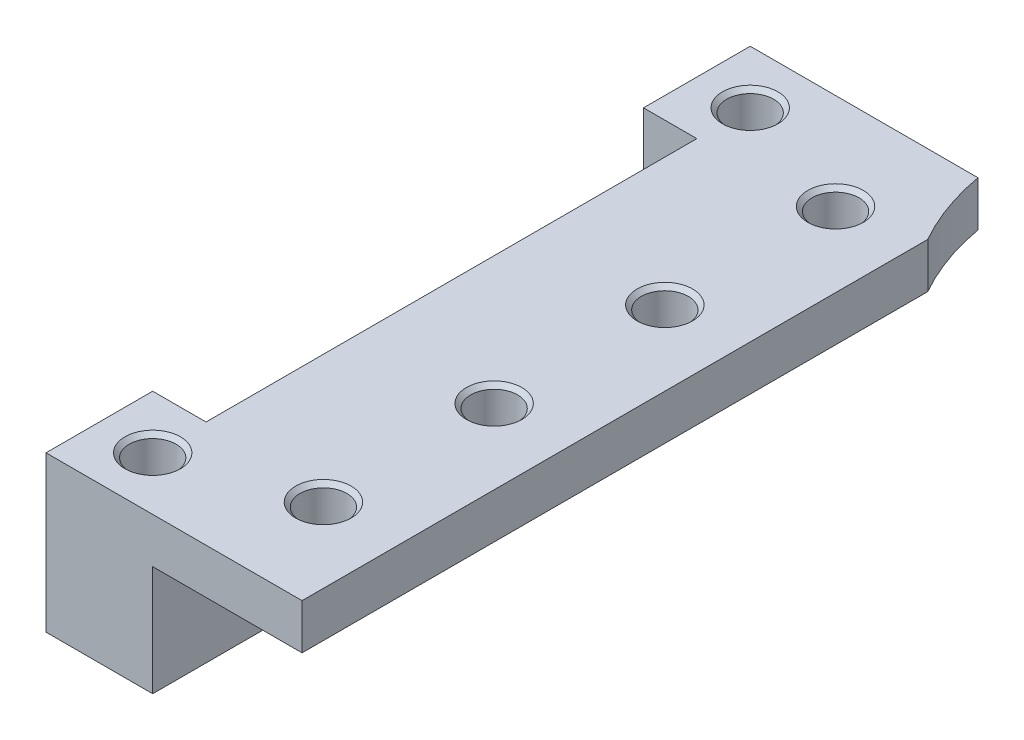
from build123d import *

# Parameters (mm, degrees)
IZIM3_W                                          = 3.5
IZIM3_H                                          = 23
IZIM3_H_2                                        = 5
IZIM3_W_2                                        = 2.5
Y_KSEKLIK_EKSTR_ZYON3_DEPTH                      = 8.28
IZIM4_W                                          = 7
IZIM4_H                                          = 5.16
KES_EKSTR_ZYON1_DEPTH                            = 34
IZIM11_W                                         = 12
IZIM11_H                                         = 33
KES_EKSTR_ZYON2_DEPTH                            = 1
M2_D_Z_BA_L_MAKINE_VIDAS_IN_HAV_A_DE_D           = 2.2
M2_D_Z_BA_L_MAKINE_VIDAS_IN_HAV_A_DE_CSINK_D     = 2.6
M2_D_Z_BA_L_MAKINE_VIDAS_IN_HAV_A_DE_CSINK_ANGLE = 90
IZIM16_W                                         = 12
IZIM16_H                                         = 33
KES_EKSTR_ZYON3_DEPTH                            = 10


with BuildPart() as part:
    # Çizim3 → Yükseklik-Ekstrüzyon3 (new body)
    with BuildSketch(Plane(origin=(0, 0, 0), x_dir=(1, 0, 0), z_dir=(0, 1, 0))):
        with BuildLine():
            Line((16, 6.5), (16, 11.5))
            Line((16, 11.5), (11.324751653, 11.5))
            ThreePointArc((11.324751653, 11.5), (10.819882158, 9.603828792), (10, 7.821091654))
            Line((10, 7.821091654), (10, -21.5))
            Line((10, -21.5), (16, -21.5))
            Line((16, -21.5), (16, -16.5))
            Line((16, -16.5), (16, 6.5))
        make_face()
        with Locations((17.75, -5)):
            Rectangle(IZIM3_W, IZIM3_H)
        with Locations((17.75, 9)):
            Rectangle(IZIM3_W, IZIM3_H_2)
        with Locations((20.75, 9)):
            Rectangle(IZIM3_W_2, IZIM3_H_2)
        with Locations((17.75, -19)):
            Rectangle(IZIM3_W, IZIM3_H_2)
        with Locations((20.75, -19)):
            Rectangle(IZIM3_W_2, IZIM3_H_2)
    y_kseklik_ekstr_zyon3 = extrude(amount=Y_KSEKLIK_EKSTR_ZYON3_DEPTH)

    # Çizim4 → Kes-Ekstrüzyon1 (cut, through all)
    with BuildSketch(Plane.XY.offset(21.5)):
        with Locations((13.5, 2.58)):
            Rectangle(IZIM4_W, IZIM4_H)
    kes_ekstr_zyon1 = extrude(amount=-KES_EKSTR_ZYON1_DEPTH, mode=Mode.SUBTRACT)

    # Çizim11 → Kes-Ekstrüzyon2 (cut)
    with BuildSketch(Plane(origin=(0, 8.28, 0), x_dir=(1, 0, 0), z_dir=(0, 1, 0))):
        with Locations((16, -5)):
            Rectangle(IZIM11_W, IZIM11_H)
    kes_ekstr_zyon2 = extrude(amount=-KES_EKSTR_ZYON2_DEPTH, mode=Mode.SUBTRACT)

    # M2 Düz Başlı Makine Vidası İçin Havşa_ DEĞİŞTİREBİLİRİZ (through all)
    with Locations(Plane(origin=(19.5, 7.28, 19), x_dir=(0, 0, 1), z_dir=(0, 1, 0))):
        with Locations((0, 0), (-28, 0), (-2, -6), (-10, -6), (-18, -6), (-26, -6)):
            m2_d_z_ba_l_makine_vidas_in_hav_a_de = CounterSinkHole(M2_D_Z_BA_L_MAKINE_VIDAS_IN_HAV_A_DE_D / 2, M2_D_Z_BA_L_MAKINE_VIDAS_IN_HAV_A_DE_CSINK_D / 2, counter_sink_angle=M2_D_Z_BA_L_MAKINE_VIDAS_IN_HAV_A_DE_CSINK_ANGLE)

    # Aynalama2: Yükseklik-Ekstrüzyon3, Kes-Ekstrüzyon1, Kes-Ekstrüzyon2, M2 Düz Başlı Makine Vidası İçin Havşa_ DEĞİŞTİREBİLİRİZ across plane
    add(y_kseklik_ekstr_zyon3.mirror(Plane(origin=(10, 8.28, 0), x_dir=(0, 0, 1), z_dir=(-1, 0, 0))))
    add(kes_ekstr_zyon1.mirror(Plane(origin=(10, 8.28, 0), x_dir=(0, 0, 1), z_dir=(-1, 0, 0))), mode=Mode.SUBTRACT)
    add(kes_ekstr_zyon2.mirror(Plane(origin=(10, 8.28, 0), x_dir=(0, 0, 1), z_dir=(-1, 0, 0))), mode=Mode.SUBTRACT)
    add(m2_d_z_ba_l_makine_vidas_in_hav_a_de.mirror(Plane(origin=(10, 8.28, 0), x_dir=(0, 0, 1), z_dir=(-1, 0, 0))), mode=Mode.SUBTRACT)

    # Çizim16 → Kes-Ekstrüzyon3 (cut)
    with BuildSketch(Plane(origin=(0, 7.28, 0), x_dir=(1, 0, 0), z_dir=(0, 1, 0))):
        with Locations((16, -5)):
            Rectangle(IZIM16_W, IZIM16_H)
    extrude(amount=-KES_EKSTR_ZYON3_DEPTH, mode=Mode.SUBTRACT)


solid = part.part
